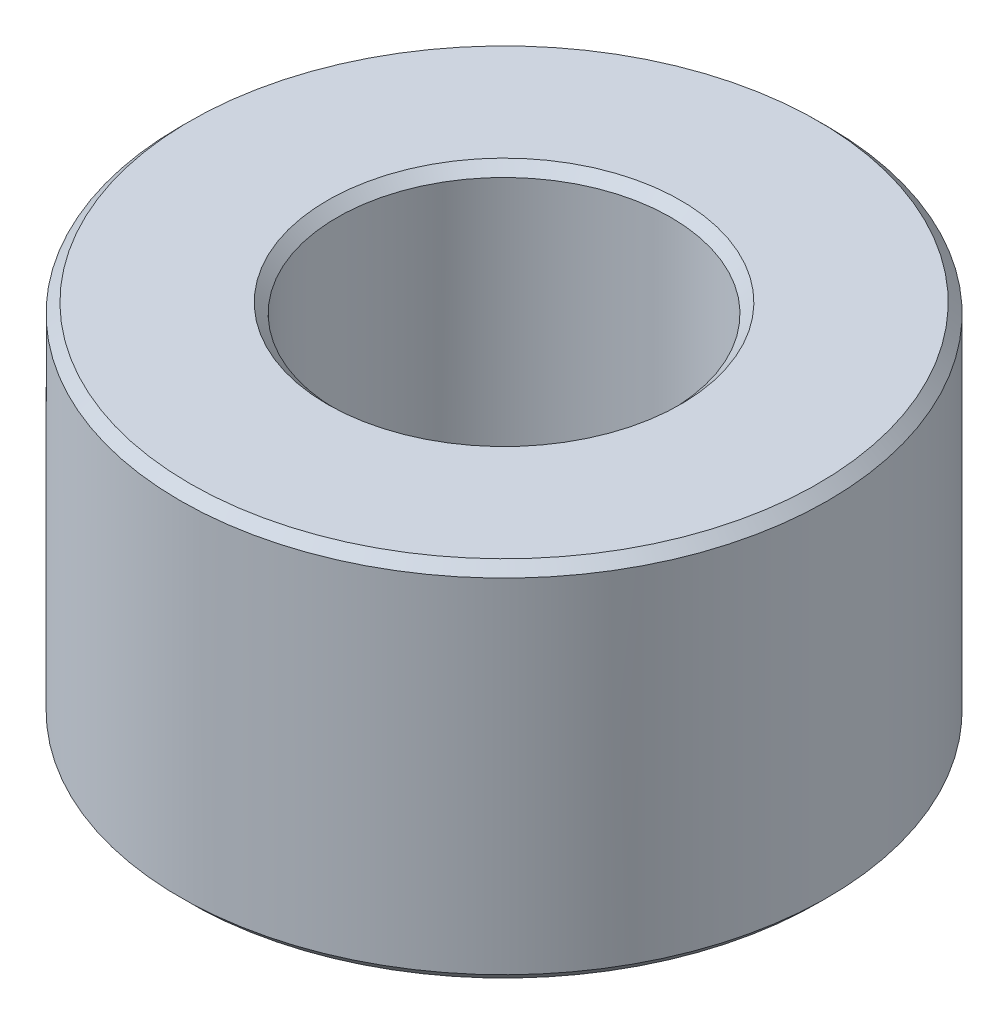
from build123d import *

# Parameters (mm, degrees)
SKETCH1_R                = 16.5
SKETCH1_R_2              = 8.5
BOSS_EXTRUDE1_DEPTH      = 15.5
SKETCH2_R                = 16.5
SKETCH2_R_2              = 2.15
BOSS_EXTRUDE2_DEPTH      = 3
BOSS_EXTRUDE2_DEPTH_BACK = 1
CHAMFER2_SIZE            = 0.5
CHAMFER3_SIZE            = 2


with BuildPart() as part:
    # Sketch1 → Boss-Extrude1 (new body)
    with BuildSketch(Plane(origin=(0, 0, 0), x_dir=(1, 0, 0), z_dir=(0, 1, 0))):
        Circle(SKETCH1_R)
        Circle(SKETCH1_R_2, mode=Mode.SUBTRACT)
    extrude(amount=BOSS_EXTRUDE1_DEPTH)

    # Sketch2 → Boss-Extrude2 (add, two sides)
    with BuildSketch(Plane.XZ) as boss_extrude2_sk:
        Circle(SKETCH2_R)
        Circle(SKETCH2_R_2, mode=Mode.SUBTRACT)
    extrude(amount=BOSS_EXTRUDE2_DEPTH)
    extrude(boss_extrude2_sk.sketch, amount=-BOSS_EXTRUDE2_DEPTH_BACK)

    # Chamfer2
    chamfer2_edges = [part.edges().sort_by_distance(p)[0] for p in [
        (-16.5, -3, 0),
        (-16.5, 15.5, 0),
        (-8.5, 15.5, 0),
    ]]
    chamfer(chamfer2_edges, length=CHAMFER2_SIZE)

    # Chamfer3
    chamfer3_edges = [part.edges().sort_by_distance(p)[0] for p in [
        (-8.5, 1, 0),
    ]]
    chamfer(chamfer3_edges, length=CHAMFER3_SIZE)


solid = part.part
